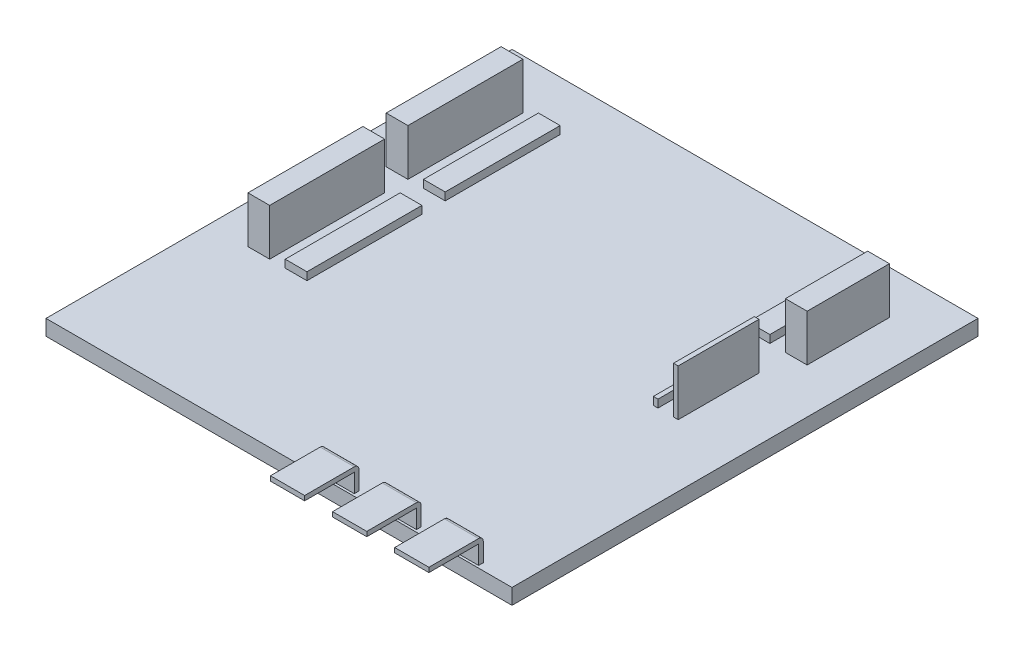
from build123d import *

# Parameters (mm, degrees)
SKETCH1_W           = 76.2
SKETCH1_H           = 76.2
EXTRUDE1_DEPTH      = 2.54
SKETCH2_W           = 3.556
SKETCH2_H           = 13.462
SKETCH2_W_2         = 0.762
SKETCH2_H_2         = 13.208
SKETCH2_H_3         = 18.796
EXTRUDE2_DEPTH      = 1.27
EXTRUDE2_DEPTH_BACK = 10.1601
SKETCH3_W           = 5.588
SKETCH3_H           = 0.762
EXTRUDE3_DEPTH      = 3.048
LPATTERN1_COUNT     = 3
LPATTERN1_PITCH     = 10.16
SKETCH8_W           = 5.588
SKETCH8_H           = 0.762
REVOLVE3_ANGLE      = 90
SKETCH9_W           = 5.588
SKETCH9_H           = 0.762
EXTRUDE5_DEPTH      = 8.128
LPATTERN2_COUNT     = 3
LPATTERN2_PITCH     = 10.16
SKETCH11_W          = 3.556
SKETCH11_H          = 18.796
SKETCH11_W_2        = 0.762
SKETCH11_H_2        = 13.208
SKETCH11_H_3        = 13.462
EXTRUDE6_DEPTH      = 6.35
SKETCH12_W          = 3.556
SKETCH12_H          = 18.796
SKETCH12_H_2        = 13.462
SKETCH12_W_2        = 0.762
SKETCH12_H_3        = 13.208
EXTRUDE7_DEPTH      = 7.6201


with BuildPart() as part:
    # Sketch1 → Extrude1 (new body)
    with BuildSketch(Plane(origin=(0, 0, 0), x_dir=(1, 0, 0), z_dir=(0, 1, 0))):
        Rectangle(SKETCH1_W, SKETCH1_H)
    extrude(amount=EXTRUDE1_DEPTH)

    # Sketch2 → Extrude2 (add, two sides)
    with BuildSketch(Plane(origin=(0, 2.54, 0), x_dir=(-1, 0, 0), z_dir=(0, 1, 0))) as extrude2_sk:
        with Locations((-22.86, -24.257)):
            Rectangle(SKETCH2_W, SKETCH2_H)
        with Locations((-24.257, -5.842)):
            Rectangle(SKETCH2_W_2, SKETCH2_H_2)
        with Locations((23.876, -20.574)):
            Rectangle(SKETCH2_W, SKETCH2_H_3)
        with Locations((23.876, 2.032)):
            Rectangle(SKETCH2_W, SKETCH2_H_3)
        with Locations((29.972, -20.574)):
            Rectangle(SKETCH2_W, SKETCH2_H_3)
        with Locations((29.972, 2.032)):
            Rectangle(SKETCH2_W, SKETCH2_H_3)
        with Locations((-28.956, -24.257)):
            Rectangle(SKETCH2_W, SKETCH2_H)
        with Locations((-27.559, -5.842)):
            Rectangle(SKETCH2_W_2, SKETCH2_H_2)
    extrude(amount=EXTRUDE2_DEPTH)
    extrude(extrude2_sk.sketch, amount=-EXTRUDE2_DEPTH_BACK)

    # Sketch3 → Extrude3 (add)
    with BuildSketch(Plane(origin=(0, 2.54, 0), x_dir=(-1, 0, 0), z_dir=(0, 1, 0))):
        with Locations((-9.144, 37.338)):
            Rectangle(SKETCH3_W, SKETCH3_H)
    extrude3 = extrude(amount=EXTRUDE3_DEPTH)

    # LPattern1: Extrude3 ×3
    with Locations(*[(i * LPATTERN1_PITCH, 0, 0) for i in range(1, LPATTERN1_COUNT)]):
        add(extrude3)

    # Sketch8 → Revolve3 (revolve)
    with BuildSketch(Plane(origin=(0, 5.588, 0), x_dir=(1, 0, 0), z_dir=(0, 1, 0))):
        with Locations((9.144, -37.338)):
            Rectangle(SKETCH8_W, SKETCH8_H)
        with Locations((19.304, -37.338)):
            Rectangle(SKETCH8_W, SKETCH8_H)
        with Locations((29.464, -37.338)):
            Rectangle(SKETCH8_W, SKETCH8_H)
    revolve(axis=Axis((6.35, 5.588, 37.719), (1, 0, 0)), revolution_arc=REVOLVE3_ANGLE)

    # Sketch9 → Extrude5 (add)
    with BuildSketch(Plane.XY.offset(37.719)):
        with Locations((9.144, 5.969)):
            Rectangle(SKETCH9_W, SKETCH9_H)
    extrude5 = extrude(amount=EXTRUDE5_DEPTH)

    # LPattern2: Extrude5 ×3
    with Locations(*[(i * LPATTERN2_PITCH, 0, 0) for i in range(1, LPATTERN2_COUNT)]):
        add(extrude5)

    # Sketch11 → Extrude6 (add)
    with BuildSketch(Plane(origin=(0, 3.81, 0), x_dir=(1, 0, 0), z_dir=(0, 1, 0))):
        with Locations((-29.972, 20.574)):
            Rectangle(SKETCH11_W, SKETCH11_H)
        with Locations((-29.972, -2.032)):
            Rectangle(SKETCH11_W, SKETCH11_H)
        with Locations((27.559, 5.842)):
            Rectangle(SKETCH11_W_2, SKETCH11_H_2)
        with Locations((28.956, 24.257)):
            Rectangle(SKETCH11_W, SKETCH11_H_3)
    extrude(amount=EXTRUDE6_DEPTH)

    # Sketch12 → Extrude7 (cut)
    with BuildSketch(Plane.XZ.offset(7.6201)):
        with Locations((-29.972, -20.574)):
            Rectangle(SKETCH12_W, SKETCH12_H)
        with Locations((-29.972, 2.032)):
            Rectangle(SKETCH12_W, SKETCH12_H)
        with Locations((28.956, -24.257)):
            Rectangle(SKETCH12_W, SKETCH12_H_2)
        with Locations((27.559, -5.842)):
            Rectangle(SKETCH12_W_2, SKETCH12_H_3)
    extrude(amount=-EXTRUDE7_DEPTH, mode=Mode.SUBTRACT)


solid = part.part
